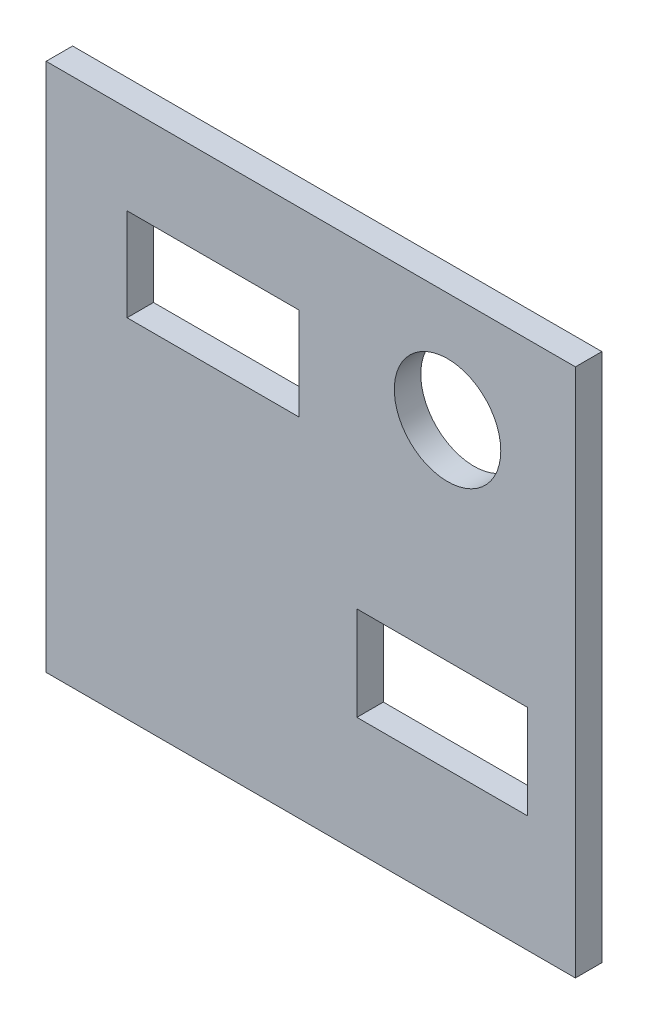
from build123d import *

# Parameters (mm, degrees)
SKETCH1_W           = 40
SKETCH1_H           = 40
SKETCH1_R           = 4.023702557
SKETCH1_W_2         = 13
SKETCH1_H_2         = 7
SKETCH1_W_3         = 12.9
SKETCH1_H_3         = 7.1
BOSS_EXTRUDE1_DEPTH = 2


with BuildPart() as part:
    # Sketch1 → Boss-Extrude1 (new body)
    with BuildSketch(Plane.XY):
        with Locations((2.018348624, -6.360856269)):
            Rectangle(SKETCH1_W, SKETCH1_H)
        with Locations((12.354740061, 5.321100917)):
            Circle(SKETCH1_R, mode=Mode.SUBTRACT)
        with Locations((-5.365443425, 3.411314985)):
            Rectangle(SKETCH1_W_2, SKETCH1_H_2, mode=Mode.SUBTRACT)
        with Locations((11.954587156, -14.008715596)):
            Rectangle(SKETCH1_W_3, SKETCH1_H_3, mode=Mode.SUBTRACT)
    extrude(amount=BOSS_EXTRUDE1_DEPTH)


solid = part.part
